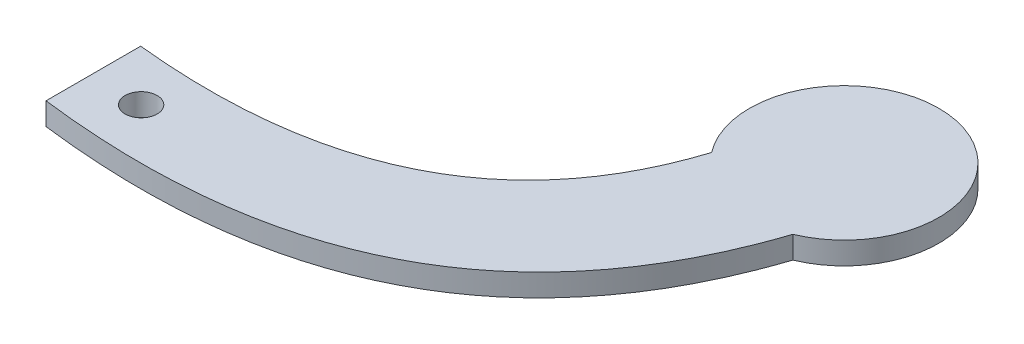
from build123d import *

# Parameters (mm, degrees)
BOSS_EXTRUDE1_DEPTH   = 3
SKETCH3_R             = 12.7
BOSS_EXTRUDE2_DEPTH   = 3
F_8_CLEARANCE_HOLE1_D = 4.3053


with BuildPart() as part:
    # Sketch2 → Boss-Extrude1 (new body)
    with BuildSketch(Plane(origin=(0, 0, 0), x_dir=(1, 0, 0), z_dir=(0, 1, 0))):
        with BuildLine():
            Line((-37.697043062, 4.281020581), (-37.697043062, -8.418979419))
            add(Edge.make_bspline(
                [(-37.697043062, -8.418979419), (17.380898097, -15.277400847), (29.368687451, 31.123681561)],
                knots=[0, 0, 0, 1, 1, 1], degree=2))
            Line((29.368687451, 31.123681561), (14.247453118, 35.062826639))
            add(Edge.make_bspline(
                [(-37.697043062, 4.281020581), (6.487978336, -0.323288205), (14.247453118, 35.062826639)],
                knots=[0, 0, 0, 1, 1, 1], degree=2))
        make_face()
    extrude(amount=BOSS_EXTRUDE1_DEPTH)

    # Sketch3 → Boss-Extrude2 (add)
    with BuildSketch(Plane(origin=(0, 0, 0), x_dir=(1, 0, 0), z_dir=(0, 1, 0))):
        with Locations((23.06337647, 37.912010101)):
            Circle(SKETCH3_R)
    extrude(amount=BOSS_EXTRUDE2_DEPTH)

    # #8 Clearance Hole1 (through all)
    with Locations(Plane(origin=(0, 3, 0), x_dir=(1, 0, 0), z_dir=(0, 1, 0))):
        with Locations((-30.855203609, -2.496063835)):
            Hole(F_8_CLEARANCE_HOLE1_D / 2)


solid = part.part
